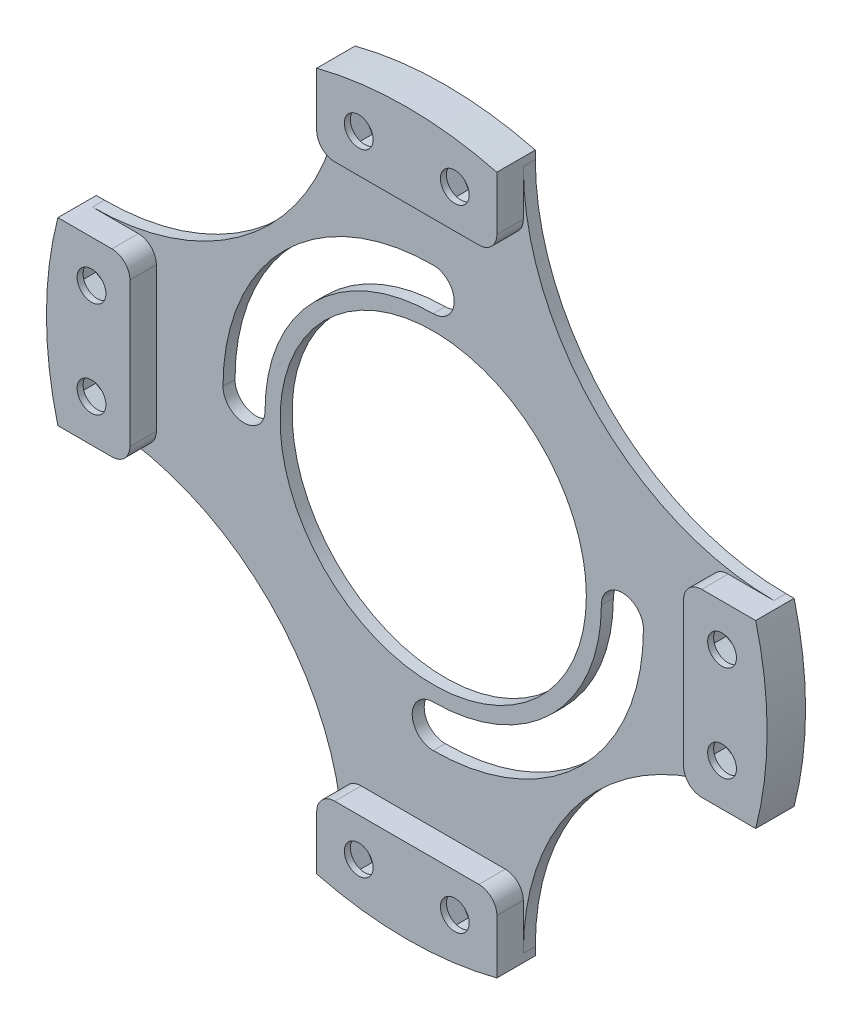
from build123d import *

# Parameters (mm, degrees)
SKIZZE1_R                         = 60
SKIZZE1_R_2                       = 25.500000000000004
AUFSATZ_LINEAR_AUSTRAGEN1_DEPTH   = 2
AUFSATZ_LINEAR_AUSTRAGEN2_DEPTH   = 3.4
AUFSATZ_LINEAR_START              = 3.4
AUFSATZ_LINEAR_AUSTRAGEN3_DEPTH   = 1
DURCHGANGSLOCH_F_R_M41_AT_2_COUNT = 2
DURCHGANGSLOCH_F_R_M41_AT_2_PITCH = 16
VERRUNDUNG1_R                     = 3
KREISMUSTER3_COUNT                = 4
VERRUNDUNG1_OF_KREISMUSTER3_R     = 3
SCHNITT_LINEAR_AUSTRAGEN1_DEPTH   = 85.96681705230577
KREISMUSTER4_COUNT                = 4


with BuildPart() as part:
    # Skizze1 → Aufsatz-Linear austragen1 (new body)
    with BuildSketch(Plane.XY):
        Circle(SKIZZE1_R)
        with BuildLine():
            ThreePointArc((27.999999999999982, 1.3878e-13), (31.499999999999975, 3.5000000000001417), (34.99999999999999, 1.663e-13))
            ThreePointArc((34.99999999999999, 1.6653e-13), (24.74873734152926, -24.748737341529065), (1.1405e-13, -35))
            ThreePointArc((1.1102e-13, -34.99999999999999), (-3.499999999999895, -31.500000000000007), (8.617e-14, -27.999999999999996))
            ThreePointArc((9.52e-14, -27.999999999999993), (19.7989898732234, -19.798989873223235), (27.99999999999998, 1.3878e-13))
        make_face(mode=Mode.SUBTRACT)
        with BuildLine():
            ThreePointArc((-35, -3.19e-15), (-24.748737341529157, 24.74873734152916), (0, 35))
            ThreePointArc((1.09e-15, 35), (3.500000000000004, 31.5), (0, 28))
            ThreePointArc((0, 27.999999999999993), (-19.79898987322333, 19.798989873223334), (-28, -1.84e-15))
            ThreePointArc((-28, 2.4e-16), (-31.5, -3.4999999999999996), (-35, 0))
        make_face(mode=Mode.SUBTRACT)
        Circle(SKIZZE1_R_2, mode=Mode.SUBTRACT)
    extrude(amount=AUFSATZ_LINEAR_AUSTRAGEN1_DEPTH)

    # Skizze2 → Aufsatz-Linear austragen2 (add)
    with BuildSketch(Plane.XY.offset(2)):
        with BuildLine():
            Line((-15, 58.09475019311125), (-15.000000000000002, 46.094750193111246))
            Line((-15.000000000000002, 46.094750193111246), (14.999999999999998, 46.094750193111246))
            Line((14.999999999999998, 46.094750193111246), (15, 58.09475019311125))
            ThreePointArc((15, 58.09475019311125), (3.67e-15, 60), (-15, 58.09475019311125))
        make_face()
        Polygon((-5.863804003998373, 56.19475019311125), (-10.13619599600161, 56.19475019311125), (-12.272391992003223, 52.49475019311125), (-10.136195996001604, 48.79475019311124), (-5.863804003998377, 48.79475019311124), (-3.7276080079967584, 52.494750193111244), align=None, mode=Mode.SUBTRACT)
        Polygon((5.863804003998377, 48.79475019311124), (3.7276080079967584, 52.494750193111244), (5.863804003998373, 56.19475019311125), (10.13619599600161, 56.19475019311125), (12.272391992003223, 52.49475019311125), (10.136195996001604, 48.79475019311124), align=None, mode=Mode.SUBTRACT)
    aufsatz_linear_austragen2 = extrude(amount=AUFSATZ_LINEAR_AUSTRAGEN2_DEPTH)

    # Skizze2_3 → Aufsatz-Linear austragen3 (add)
    with BuildSketch(Plane.XY.offset(2).offset(AUFSATZ_LINEAR_START)):
        with BuildLine():
            Line((-15, 58.09475019311125), (-15.000000000000002, 46.094750193111246))
            Line((-15.000000000000002, 46.094750193111246), (14.999999999999998, 46.094750193111246))
            Line((14.999999999999998, 46.094750193111246), (15, 58.09475019311125))
            ThreePointArc((15, 58.09475019311125), (3.67e-15, 60), (-15, 58.09475019311125))
        make_face()
    aufsatz_linear_austragen3 = extrude(amount=AUFSATZ_LINEAR_AUSTRAGEN3_DEPTH)

    # Skizze4 → Durchgangsloch für M41 (revolve, cut)
    with BuildSketch(Plane(origin=(-8, 52.494750193111244, 6.4), x_dir=(0, -1, 0), z_dir=(1, 0, 0))):
        Polygon((0, 0), (-1.61e-14, 65.74206548566613), (2.3999999999999804, 64.3), (2.399999999999989, -1.26e-15), align=None)
    durchgangsloch_f_r_m41 = revolve(axis=Axis((-8, 52.494750193111244, 12.749999999999991), (0, 0, -1)), mode=Mode.SUBTRACT)

    # Durchgangsloch für M41 at 2: Durchgangsloch für M41 ×2
    with Locations(*[(i * DURCHGANGSLOCH_F_R_M41_AT_2_PITCH, 0, 0) for i in range(1, DURCHGANGSLOCH_F_R_M41_AT_2_COUNT)]):
        add(durchgangsloch_f_r_m41, mode=Mode.SUBTRACT)

    # Verrundung1
    verrundung1_edges = [part.edges().sort_by_distance(p)[0] for p in [
        (14.999999999999998, 46.094750193111246, 4.2),
        (-15.000000000000002, 46.094750193111246, 4.2),
    ]]
    fillet(verrundung1_edges, radius=VERRUNDUNG1_R)

    # Kreismuster3: Aufsatz-Linear austragen2, Aufsatz-Linear austragen3, Durchgangsloch für M41 ×4 about axis
    kreismuster3_axis = Axis((0, 0, 2), (0, 0, 1))
    add([aufsatz_linear_austragen2.rotate(kreismuster3_axis, i * 360 / KREISMUSTER3_COUNT) for i in range(1, KREISMUSTER3_COUNT)])
    add([aufsatz_linear_austragen3.rotate(kreismuster3_axis, i * 360 / KREISMUSTER3_COUNT) for i in range(1, KREISMUSTER3_COUNT)])
    add([durchgangsloch_f_r_m41.rotate(kreismuster3_axis, i * 360 / KREISMUSTER3_COUNT) for i in range(1, KREISMUSTER3_COUNT)], mode=Mode.SUBTRACT)

    # Kreismuster3 copy 1 sketch → Kreismuster3 copy 1 (revolve, cut)
    with BuildSketch(Plane(origin=(-52.494750193111244, 8.000000000000004, 6.4), x_dir=(1, -6e-17, 0), z_dir=(6e-17, 1, 0))):
        Polygon((0, 0), (-1.61e-14, 65.74206548566613), (2.3999999999999804, 64.3), (2.399999999999989, -1.26e-15), align=None)
    revolve(axis=Axis((-52.494750193111244, 8.000000000000004, 12.749999999999991), (0, 0, -1)), mode=Mode.SUBTRACT)

    # Kreismuster3 copy 2 sketch → Kreismuster3 copy 2 (revolve, cut)
    with BuildSketch(Plane(origin=(-8.000000000000007, -52.494750193111244, 6.4), x_dir=(1.2e-16, 1, 0), z_dir=(-1, 1.2e-16, 0))):
        Polygon((0, 0), (-1.61e-14, 65.74206548566613), (2.3999999999999804, 64.3), (2.399999999999989, -1.26e-15), align=None)
    revolve(axis=Axis((-8.000000000000007, -52.494750193111244, 12.749999999999991), (0, 0, -1)), mode=Mode.SUBTRACT)

    # Kreismuster3 copy 3 sketch → Kreismuster3 copy 3 (revolve, cut)
    with BuildSketch(Plane(origin=(52.494750193111244, -8.00000000000001, 6.4), x_dir=(-1, 1.8e-16, 0), z_dir=(-1.8e-16, -1, 0))):
        Polygon((0, 0), (-1.61e-14, 65.74206548566613), (2.3999999999999804, 64.3), (2.399999999999989, -1.26e-15), align=None)
    revolve(axis=Axis((52.494750193111244, -8.00000000000001, 12.749999999999991), (0, 0, -1)), mode=Mode.SUBTRACT)

    # Verrundung1 of Kreismuster3
    verrundung1_of_kreismuster3_edges = [part.edges().sort_by_distance(p)[0] for p in [
        (-46.094750193111246, 15.000000000000002, 4.2),
        (-46.094750193111246, -14.999999999999998, 4.2),
        (-15.000000000000004, -46.094750193111246, 4.2),
        (14.999999999999996, -46.094750193111246, 4.2),
        (46.094750193111246, -15.000000000000007, 4.2),
        (46.094750193111246, 14.999999999999993, 4.2),
    ]]
    fillet(verrundung1_of_kreismuster3_edges, radius=VERRUNDUNG1_OF_KREISMUSTER3_R)

    # Skizze5 → Schnitt-Linear austragen1 (cut, through all)
    with BuildSketch(Plane.XY.offset(2)):
        with BuildLine():
            Line((58.09475019311109, 15.000000000000608), (56.734018715766695, 15.00000000000061))
            ThreePointArc((56.734018715766695, 15.00000000000061), (27.22361107568177, 27.22361107568239), (15, 56.734018715767306))
            Line((15, 56.734018715767306), (14.999999999999998, 58.09475019311125))
            ThreePointArc((14.999999999999998, 58.09475019311125), (42.426406871192626, 42.42640687119307), (58.09475019311109, 15.000000000000608))
        make_face()
    schnitt_linear_austragen1 = extrude(amount=-SCHNITT_LINEAR_AUSTRAGEN1_DEPTH, mode=Mode.SUBTRACT)

    # Kreismuster4: Schnitt-Linear austragen1 ×4 about axis
    kreismuster4_axis = Axis((0, 0, 0), (0, 0, 1))
    for i in range(1, KREISMUSTER4_COUNT):
        add(schnitt_linear_austragen1.rotate(kreismuster4_axis, i * 360 / KREISMUSTER4_COUNT), mode=Mode.SUBTRACT)


solid = part.part
